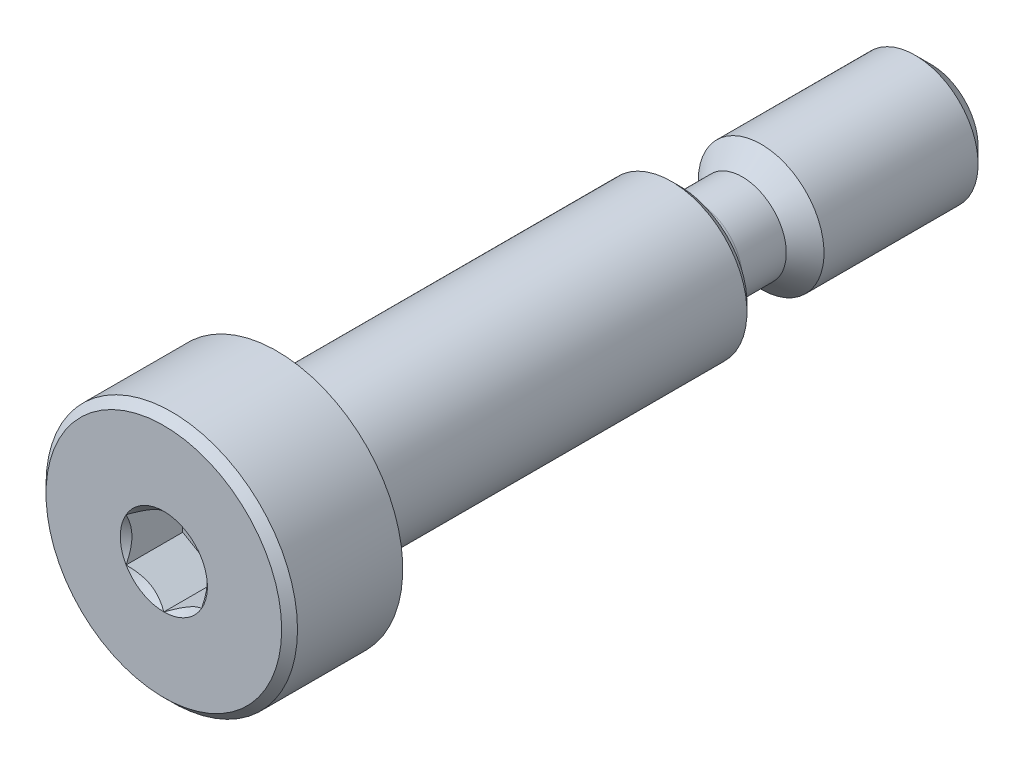
from build123d import *

# Parameters (mm, degrees)
CHAMFER1_SIZE      = 0.625
CHAMFER2_SIZE      = 0.315
CUT_EXTRUDE3_DEPTH = 2.25


with BuildPart() as part:
    # Sketch1 → Revolve1 (revolve)
    with BuildSketch(Plane(origin=(0, 0, 0), x_dir=(0, 0, -1), z_dir=(1, 0, 0))):
        Polygon((0, 5), (4.5, 5), (4.5, 3), (20.5, 3), (20.5, 2.5), (30.5, 2.5), (30.5, 0), (0, 0), align=None)
    revolve(axis=Axis((0, 0, -30.5), (0, 0, 1)))

    # Sketch5 → Cut-Revolve1 (revolve, cut)
    with BuildSketch(Plane(origin=(0, 0, 0), x_dir=(0, 0, -1), z_dir=(1, 0, 0))):
        with BuildLine():
            Line((20.5, 3), (24.250000008, 3))
            Line((24.250000008, 3), (23, 1.749999993))
            Line((23, 1.749999993), (21.250000008, 1.749999993))
            ThreePointArc((21.250000008, 1.749999993), (20.719669916, 1.969669909), (20.5, 2.5))
            Line((20.5, 2.5), (20.5, 3))
        make_face()
    revolve(axis=Axis((0, 0, -30.5), (0, 0, 1)), mode=Mode.SUBTRACT)

    # Chamfer1
    chamfer1_edges = [part.edges().sort_by_distance(p)[0] for p in [
        (0, -2.5, -30.5),
    ]]
    chamfer(chamfer1_edges, length=CHAMFER1_SIZE)

    # Chamfer2
    chamfer2_edges = [part.edges().sort_by_distance(p)[0] for p in [
        (0, -5, 0),
        (0, -3, -20.5),
    ]]
    chamfer(chamfer2_edges, length=CHAMFER2_SIZE)

    # Sketch8 → Cut-Extrude3 (cut)
    with BuildSketch(Plane.XY):
        Polygon((1.5, 0.866025404), (0, 1.732050808), (-1.5, 0.866025404), (-1.5, -0.866025404), (0, -1.732050808), (1.5, -0.866025404), align=None)
    extrude(amount=-CUT_EXTRUDE3_DEPTH, mode=Mode.SUBTRACT)

    # Cut-Extrude4 cone 1 section (through the dimple's axis) → Cut-Extrude4 (revolve, cut)
    with BuildSketch(Plane(origin=(0, 0, 0), x_dir=(0, -1, 0), z_dir=(1, 0, 0))):
        Polygon((0, 0), (1.732050808, 0), (0, 1.732050808), align=None)
    revolve(axis=Axis((0, 0, 0), (0, 0, -1)), mode=Mode.SUBTRACT)


solid = part.part
